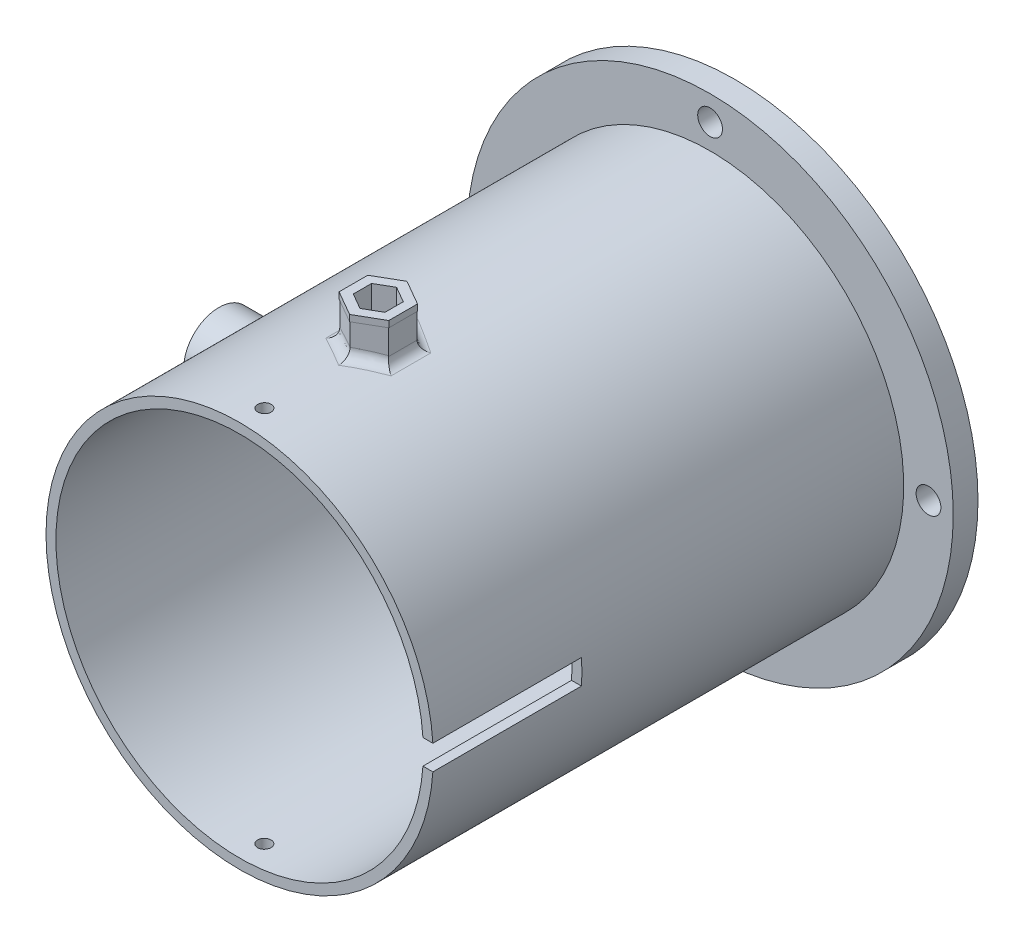
from build123d import *

# Parameters (mm, degrees)
SKETCH1_R                  = 49.657
SKETCH1_R_2                = 47.117
BOSS_EXTRUDE1_DEPTH        = 63.5
BOSS_EXTRUDE2_START        = -6.35
SKETCH2_R                  = 62.357
SKETCH2_R_2                = 49.657
BOSS_EXTRUDE2_DEPTH        = 6.35
F_1_4_0_2500_DOWEL_HOLE1_D = 6.35
SKETCH10_W                 = 38.1
SKETCH10_H                 = 6.35
CUT_EXTRUDE1_DEPTH         = 109.669411109
SKETCH12_R                 = 3.175
CUT_EXTRUDE3_DEPTH         = 109.669411109
BOSS_EXTRUDE3_START        = -48.768
SKETCH13_R                 = 9.017
SKETCH13_R_2               = 6.477
BOSS_EXTRUDE3_DEPTH        = 20.066
CUT_EXTRUDE4_REACH         = 114.511
SKETCH14_R                 = 3.429
SKETCH14_R_2               = 3.175
CUT_EXTRUDE5_REACH         = 114.511
SKETCH15_R                 = 1.905
BOSS_EXTRUDE4_START        = 49.022
BOSS_EXTRUDE4_DEPTH        = 8.89
FILLET3_R                  = 2.54
BOSS_EXTRUDE5_DEPTH        = 1.6256
FILLET4_R                  = 2.54


with BuildPart() as part:
    # Sketch1 → Boss-Extrude1 (new, symmetric)
    with BuildSketch(Plane.XY):
        Circle(SKETCH1_R)
        Circle(SKETCH1_R_2, mode=Mode.SUBTRACT)
    extrude(amount=BOSS_EXTRUDE1_DEPTH, both=True)

    # Sketch2 → Boss-Extrude2 (add)
    with BuildSketch(Plane(origin=(0, 0, -63.5), x_dir=(-1, 0, 0), z_dir=(0, 0, -1)).offset(BOSS_EXTRUDE2_START)):
        Circle(SKETCH2_R)
        Circle(SKETCH2_R_2, mode=Mode.SUBTRACT)
    extrude(amount=BOSS_EXTRUDE2_DEPTH)

    # Sketch5 → 8-32 Tapped Hole1 (revolve, cut)
    with BuildSketch(Plane(origin=(0, 0, 57.15), x_dir=(0, 0, -1), z_dir=(1, 0, 0))):
        Polygon((0, 0), (0, 62.357), (1.7272, 62.357), (1.7272, 0.9906), (2.7178, 0), align=None)
    f_8_32_tapped_hole1 = revolve(axis=Axis((0, -6.35, 57.15), (0, 1, 0)), mode=Mode.SUBTRACT)

    # Mirror1: 8-32 Tapped Hole1 across plane
    add(f_8_32_tapped_hole1.mirror(Plane.ZX), mode=Mode.SUBTRACT)

    # 1_4 _0.2500_ Dowel Hole1 (through all)
    with Locations(Plane.XY.offset(-57.15)):
        with Locations((-56.007, 0), (0, 56.007), (56.007, 0), (0, -56.007)):
            Hole(F_1_4_0_2500_DOWEL_HOLE1_D / 2)

    # Sketch10 → Cut-Extrude1 (cut, through all)
    with BuildSketch(Plane(origin=(0, 0, 0), x_dir=(0, 0, -1), z_dir=(1, 0, 0))):
        with Locations((-44.45, 0)):
            Rectangle(SKETCH10_W, SKETCH10_H)
    extrude(amount=CUT_EXTRUDE1_DEPTH, mode=Mode.SUBTRACT)

    # Sketch12 → Cut-Extrude3 (cut, through all)
    with BuildSketch(Plane(origin=(0, 0, 0), x_dir=(0, 0, -1), z_dir=(1, 0, 0))):
        Circle(SKETCH12_R)
    extrude(amount=-CUT_EXTRUDE3_DEPTH, mode=Mode.SUBTRACT)

    # Sketch13 → Boss-Extrude3 (add)
    with BuildSketch(Plane(origin=(0, 0, 0), x_dir=(0, 0, -1), z_dir=(1, 0, 0)).offset(BOSS_EXTRUDE3_START)):
        Circle(SKETCH13_R)
        Circle(SKETCH13_R_2, mode=Mode.SUBTRACT)
    extrude(amount=-BOSS_EXTRUDE3_DEPTH)

    # Sketch14 → Cut-Extrude4 (cut, up to next)
    with BuildSketch(Plane(origin=(0, 0, 0), x_dir=(0, 0, -1), z_dir=(1, 0, 0)), mode=Mode.PRIVATE) as cut_extrude4_sk1:
        Circle(SKETCH14_R)
        Circle(SKETCH14_R_2, mode=Mode.SUBTRACT)
    cut_extrude4_tool1 = extrude(cut_extrude4_sk1.sketch, amount=-CUT_EXTRUDE4_REACH, mode=Mode.PRIVATE) & part.part
    add(cut_extrude4_tool1.solids().sort_by_distance((0, 0, 3.332013))[0], mode=Mode.SUBTRACT)

    # Sketch15 → Cut-Extrude5 (cut, up to next)
    with BuildSketch(Plane(origin=(0, 0, 0), x_dir=(1, 0, 0), z_dir=(0, 1, 0)), mode=Mode.PRIVATE) as cut_extrude5_sk1:
        with Locations((0, -27.94)):
            Circle(SKETCH15_R)
    cut_extrude5_tool1 = extrude(cut_extrude5_sk1.sketch, amount=CUT_EXTRUDE5_REACH, mode=Mode.PRIVATE) & part.part
    add(cut_extrude5_tool1.solids().sort_by_distance((0, 0, 27.94))[0], mode=Mode.SUBTRACT)

    # Sketch16 → Boss-Extrude4 (add)
    with BuildSketch(Plane(origin=(0, 0, 0), x_dir=(1, 0, 0), z_dir=(0, 1, 0)).offset(BOSS_EXTRUDE4_START)):
        Polygon((-6.263704526, -31.556351494), (0, -35.172702988), (6.263704526, -31.556351494), (6.263704526, -24.323648506), (0, -20.707297012), (-6.263704526, -24.323648506), align=None)
        Polygon((-4.064, -30.286351494), (-4.064, -25.593648506), (0, -23.247297012), (4.064, -25.593648506), (4.064, -30.286351494), (0, -32.632702988), align=None, mode=Mode.SUBTRACT)
    extrude(amount=BOSS_EXTRUDE4_DEPTH)

    # Fillet3
    fillet3_edges = [part.edges().sort_by_distance(p)[0] for p in [
        (-3.136562658, 49.557841193, 22.518192307),
        (-6.263704526, 49.260365961, 27.94),
        (3.136562658, 49.557841193, 22.518192307),
        (6.263704526, 49.260365961, 27.94),
        (-3.136562658, 49.557841193, 33.361807693),
        (3.136562658, 49.557841193, 33.361807693),
    ]]
    fillet(fillet3_edges, radius=FILLET3_R)

    # Sketch17 → Boss-Extrude5 (add)
    with BuildSketch(Plane(origin=(0, 57.912, 0), x_dir=(1, 0, 0), z_dir=(0, 1, 0))):
        Polygon((-6.374687849, -31.620427746), (0, -35.300855491), (6.374687849, -31.620427746), (6.374687849, -24.259572254), (0, -20.579144509), (-6.374687849, -24.259572254), align=None)
        Polygon((-4.064, -30.286351494), (0, -32.632702988), (4.064, -30.286351494), (4.064, -25.593648506), (0, -23.247297012), (-4.064, -25.593648506), align=None, mode=Mode.SUBTRACT)
    extrude(amount=BOSS_EXTRUDE5_DEPTH)

    # Fillet4
    fillet4_edges = [part.edges().sort_by_distance(p)[0] for p in [
        (-49.657, 0, 9.017),
    ]]
    fillet(fillet4_edges, radius=FILLET4_R)


solid = part.part
